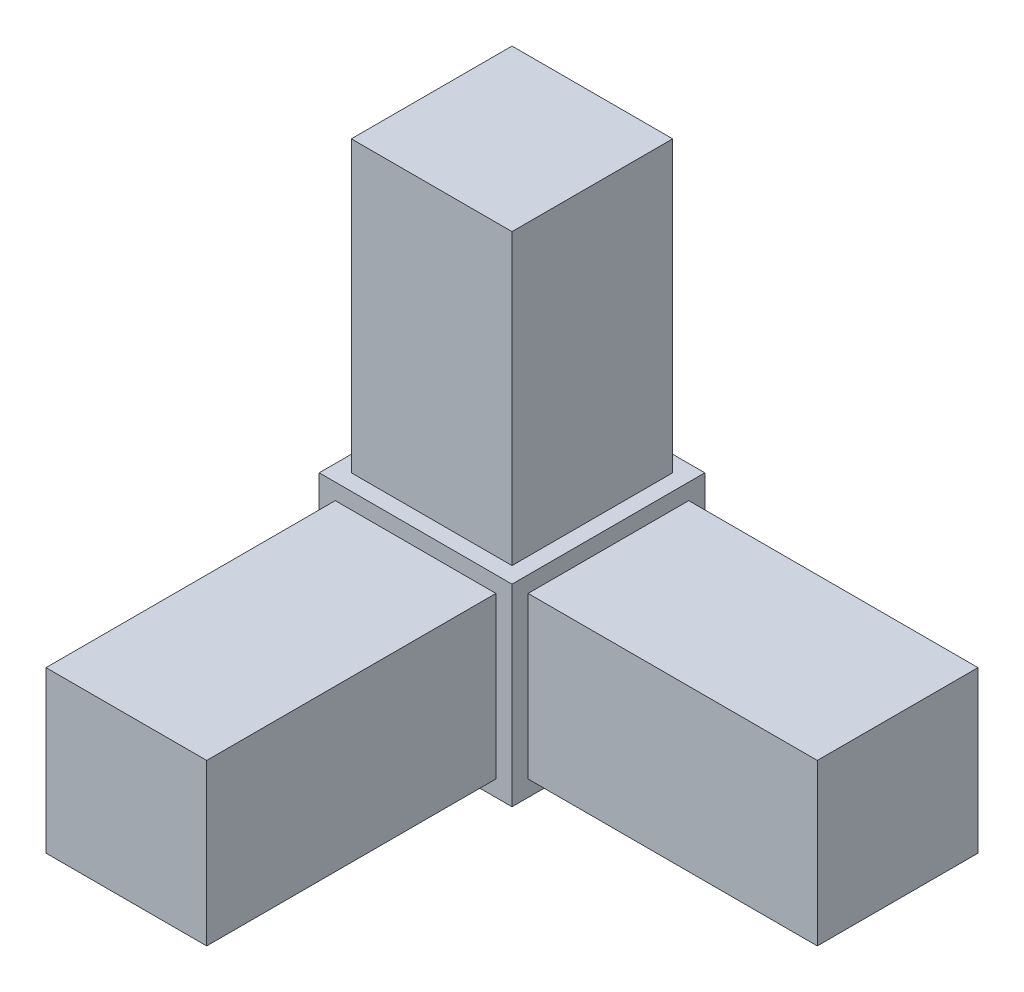
from build123d import *

# Parameters (mm, degrees)
SKETCH1_W           = 19.05
SKETCH1_H           = 19.05
BOSS_EXTRUDE1_DEPTH = 19.05
SKETCH2_W           = 15.875
SKETCH2_H           = 15.875
BOSS_EXTRUDE2_DEPTH = 28.575
SKETCH3_W           = 15.875
SKETCH3_H           = 15.875
BOSS_EXTRUDE3_DEPTH = 28.575
SKETCH4_W           = 15.875
SKETCH4_H           = 15.875
BOSS_EXTRUDE4_DEPTH = 28.575


with BuildPart() as part:
    # Sketch1 → Boss-Extrude1 (new body)
    with BuildSketch(Plane.XY):
        Rectangle(SKETCH1_W, SKETCH1_H)
    extrude(amount=BOSS_EXTRUDE1_DEPTH)

    # Sketch2 → Boss-Extrude2 (add)
    with BuildSketch(Plane(origin=(0, 9.525, 0), x_dir=(1, 0, 0), z_dir=(0, 1, 0))):
        with Locations((0, -9.525)):
            Rectangle(SKETCH2_W, SKETCH2_H)
    extrude(amount=BOSS_EXTRUDE2_DEPTH)

    # Sketch3 → Boss-Extrude3 (add)
    with BuildSketch(Plane(origin=(9.525, 0, 0), x_dir=(0, 0, -1), z_dir=(1, 0, 0))):
        with Locations((-9.525, 0)):
            Rectangle(SKETCH3_W, SKETCH3_H)
    extrude(amount=BOSS_EXTRUDE3_DEPTH)

    # Sketch4 → Boss-Extrude4 (add)
    with BuildSketch(Plane.XY.offset(19.05)):
        Rectangle(SKETCH4_W, SKETCH4_H)
    extrude(amount=BOSS_EXTRUDE4_DEPTH)


solid = part.part
